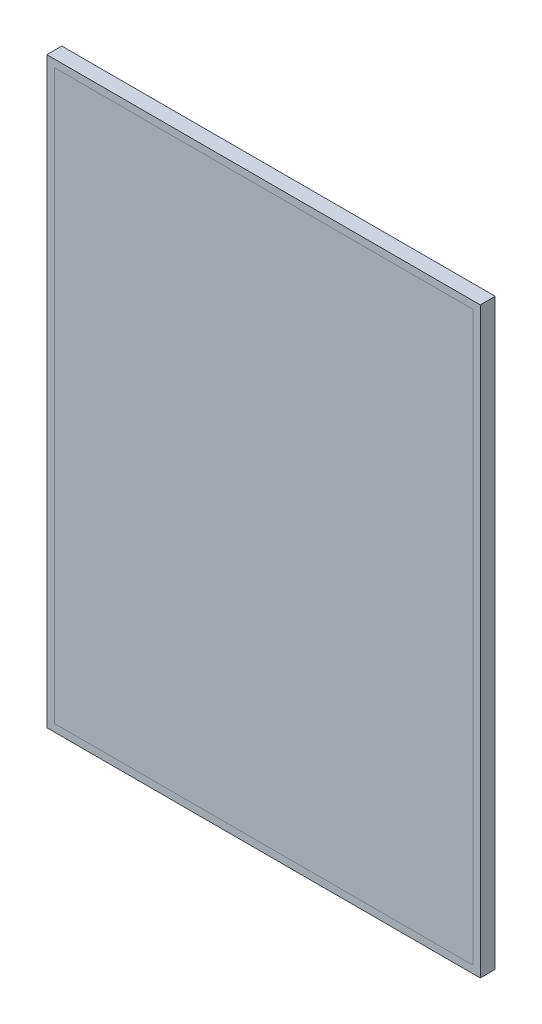
from build123d import *

# Parameters (mm, degrees)
SKETCH1_W           = 290
SKETCH1_H           = 390
SKETCH1_W_2         = 280
SKETCH1_H_2         = 380
BOSS_EXTRUDE1_DEPTH = 10
SKETCH2_W           = 280
SKETCH2_H           = 380
BOSS_EXTRUDE2_DEPTH = 1


with BuildPart() as part:
    # Sketch1 → Boss-Extrude1 (new body)
    with BuildSketch(Plane.XY):
        Rectangle(SKETCH1_W, SKETCH1_H)
        Rectangle(SKETCH1_W_2, SKETCH1_H_2, mode=Mode.SUBTRACT)
    extrude(amount=BOSS_EXTRUDE1_DEPTH)


with BuildPart() as body_2:
    # Sketch2 → Boss-Extrude2 (new body)
    with BuildSketch(Plane.XY.offset(10)):
        Rectangle(SKETCH2_W, SKETCH2_H)
    extrude(amount=-BOSS_EXTRUDE2_DEPTH)


solid = Compound([part.part, body_2.part])
